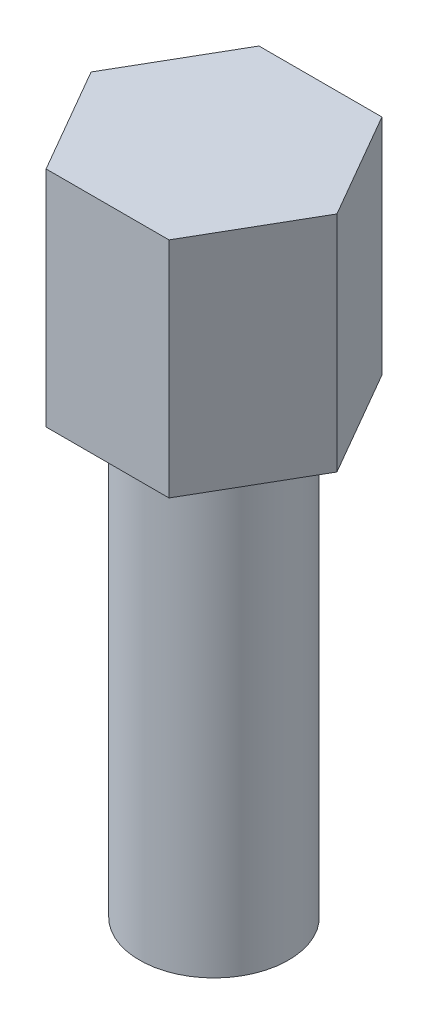
from build123d import *

# Parameters (mm, degrees)
BOSS_EXTRUDE1_DEPTH = 3
SKETCH2_R           = 1
BOSS_EXTRUDE2_DEPTH = 6


with BuildPart() as part:
    # Sketch1 → Boss-Extrude1 (new body)
    with BuildSketch(Plane(origin=(0, 0, 0), x_dir=(1, 0, 0), z_dir=(0, 1, 0))):
        Polygon((1.65, 0), (0.825, 1.428941916), (-0.825, 1.428941916), (-1.65, 0), (-0.825, -1.428941916), (0.825, -1.428941916), align=None)
    extrude(amount=BOSS_EXTRUDE1_DEPTH)

    # Sketch2 → Boss-Extrude2 (add)
    with BuildSketch(Plane.XZ):
        Circle(SKETCH2_R)
    extrude(amount=BOSS_EXTRUDE2_DEPTH)


solid = part.part
